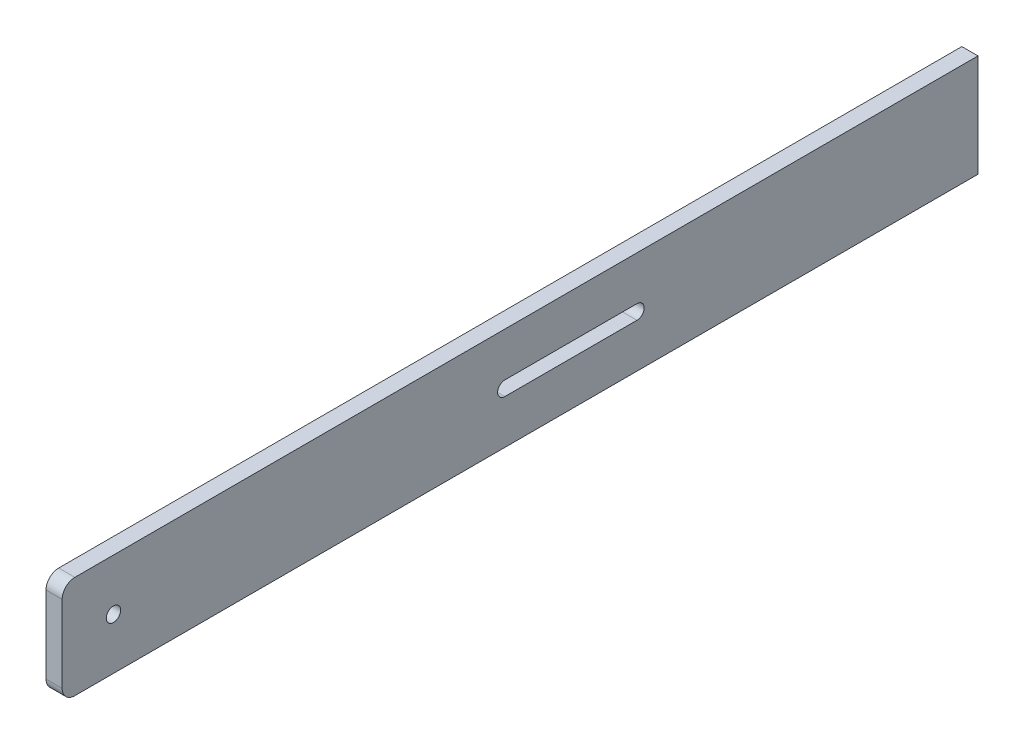
from build123d import *

# Parameters (mm, degrees)
SKETCH1_W           = 3.175
SKETCH1_H           = 20.17
BOSS_EXTRUDE1_DEPTH = 180.17
SKETCH6_R           = 1.415
CUT_EXTRUDE1_DEPTH  = 4.175
FILLET1_R           = 2.5
CUT_EXTRUDE3_DEPTH  = 10


with BuildPart() as part:
    # Sketch1 → Boss-Extrude1 (new body)
    with BuildSketch(Plane.XY):
        Rectangle(SKETCH1_W, SKETCH1_H)
    extrude(amount=BOSS_EXTRUDE1_DEPTH)

    # Sketch6 → Cut-Extrude1 (cut, through all)
    with BuildSketch(Plane(origin=(1.5875, 0, 0), x_dir=(0, 0, -1), z_dir=(1, 0, 0))):
        with Locations((-170.08, 0)):
            Circle(SKETCH6_R)
    extrude(amount=-CUT_EXTRUDE1_DEPTH, mode=Mode.SUBTRACT)

    # Fillet1
    fillet1_edges = [part.edges().sort_by_distance(p)[0] for p in [
        (0, -10.085, 180.17),
        (0, 10.085, 180.17),
    ]]
    fillet(fillet1_edges, radius=FILLET1_R)

    # Sketch7 → Cut-Extrude3 (cut)
    with BuildSketch(Plane.ZY.offset(1.5875)):
        with BuildLine():
            Line((67.085, 1.415), (93.085, 1.415))
            ThreePointArc((93.085, 1.415), (94.5, 0), (93.085, -1.415))
            Line((93.085, -1.415), (67.085, -1.415))
            ThreePointArc((67.085, -1.415), (65.67, 0), (67.085, 1.415))
        make_face()
    extrude(amount=-CUT_EXTRUDE3_DEPTH, mode=Mode.SUBTRACT)


solid = part.part
